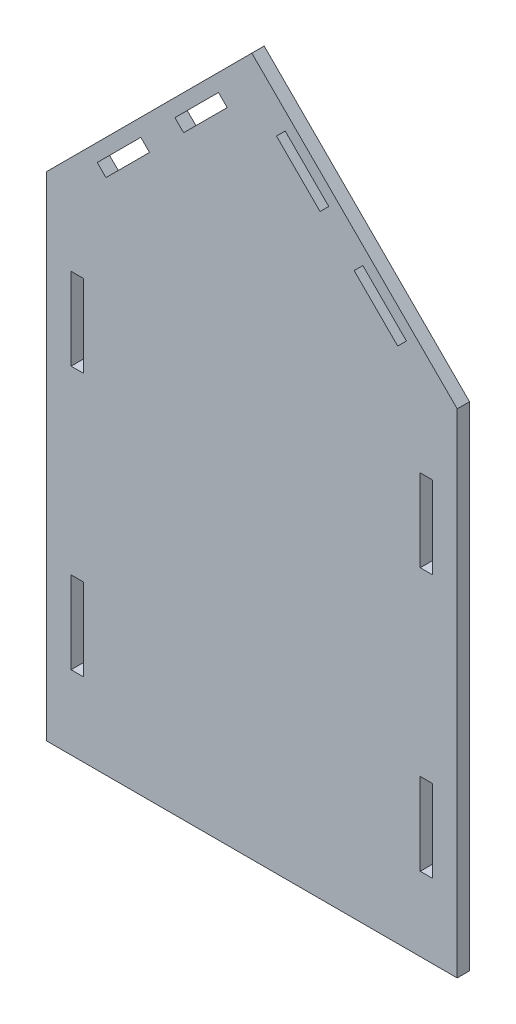
from build123d import *

# Parameters (mm, degrees)
SKETCH1_W           = 15
SKETCH1_H           = 100
BOSS_EXTRUDE1_DEPTH = 15


with BuildPart() as part:
    # Sketch1 → Boss-Extrude1 (new body)
    with BuildSketch(Plane.XY):
        Polygon((0, 0), (0, 600), (250, 850), (500, 600), (500, 0), align=None)
        with Locations((37.5, 460)):
            Rectangle(SKETCH1_W, SKETCH1_H, mode=Mode.SUBTRACT)
        with Locations((462.5, 460)):
            Rectangle(SKETCH1_W, SKETCH1_H, mode=Mode.SUBTRACT)
        with Locations((462.5, 140)):
            Rectangle(SKETCH1_W, SKETCH1_H, mode=Mode.SUBTRACT)
        with Locations((37.5, 140)):
            Rectangle(SKETCH1_W, SKETCH1_H, mode=Mode.SUBTRACT)
        Polygon((61.819805153, 640.606601718), (72.426406871, 630), (125.45941546, 683.033008589), (114.852813742, 693.639610307), align=None, mode=Mode.SUBTRACT)
        Polygon((166.966991411, 724.54058454), (156.360389693, 735.147186258), (209.393398282, 788.180194847), (220, 777.573593129), align=None, mode=Mode.SUBTRACT)
        Polygon((280, 777.573593129), (333.033008589, 724.54058454), (343.639610307, 735.147186258), (290.606601718, 788.180194847), align=None, mode=Mode.SUBTRACT)
        Polygon((374.54058454, 683.033008589), (385.147186258, 693.639610307), (438.180194847, 640.606601718), (427.573593129, 630), align=None, mode=Mode.SUBTRACT)
    extrude(amount=BOSS_EXTRUDE1_DEPTH)


solid = part.part
